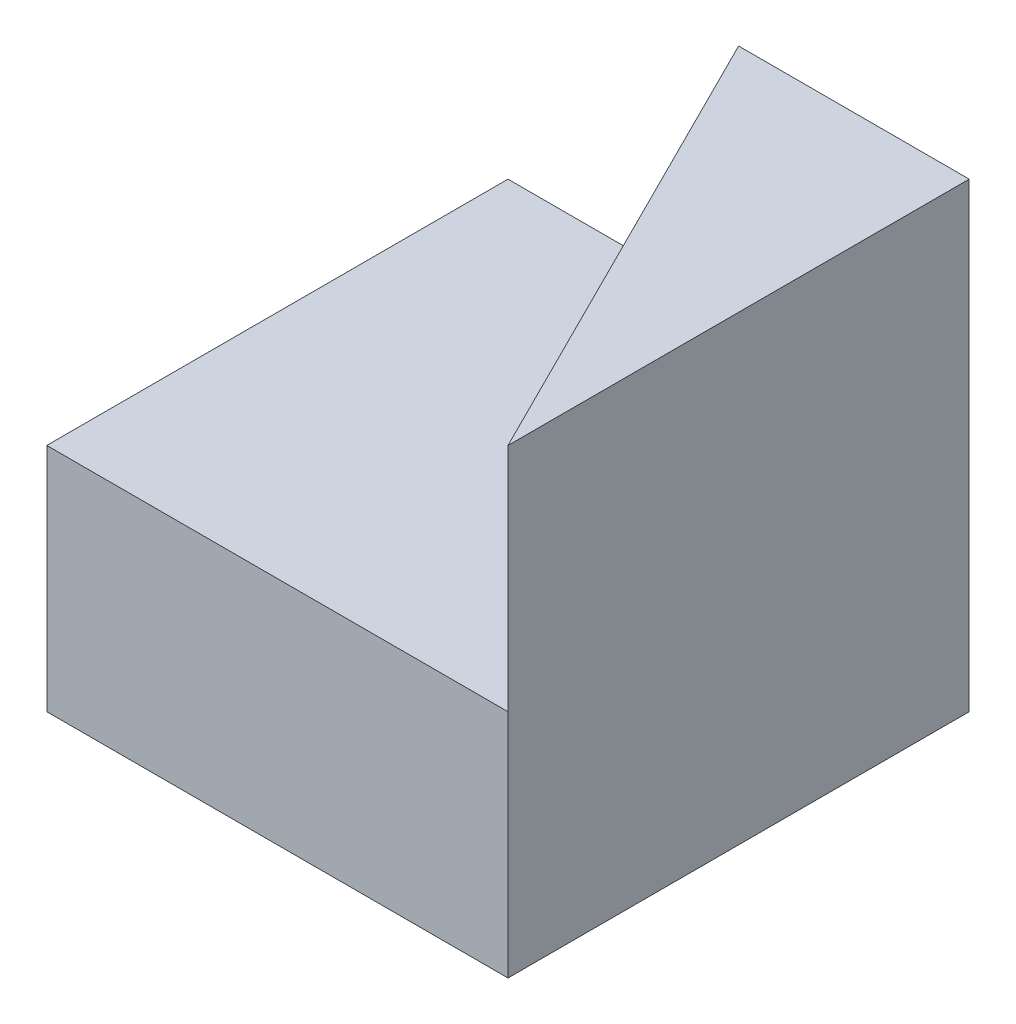
from build123d import *

# Parameters (mm, degrees)
SKETCH1_W           = 40
SKETCH1_H           = 20
BOSS_EXTRUDE2_DEPTH = 40
CUT_EXTRUDE1_DEPTH  = 40
BOSS_EXTRUDE3_DEPTH = 20
BOSS_EXTRUDE4_DEPTH = 20
CUT_EXTRUDE2_DEPTH  = 20
SKETCH6_W           = 20
SKETCH6_H           = 20
CUT_EXTRUDE3_DEPTH  = 109
BOSS_EXTRUDE5_DEPTH = 20
BOSS_EXTRUDE6_DEPTH = 20
CUT_EXTRUDE5_DEPTH  = 20


with BuildPart() as part:
    # Sketch1 → Boss-Extrude2 (new body)
    with BuildSketch(Plane.XY):
        with Locations((20, 10)):
            Rectangle(SKETCH1_W, SKETCH1_H)
    extrude(amount=BOSS_EXTRUDE2_DEPTH)

    # Sketch2 → Cut-Extrude1 (cut)
    with BuildSketch(Plane(origin=(0, 20, 0), x_dir=(1, 0, 0), z_dir=(0, 1, 0))):
        Polygon((0, -40), (20, 0), (0, 0), align=None)
    extrude(amount=-CUT_EXTRUDE1_DEPTH, mode=Mode.SUBTRACT)

    # Sketch3 → Boss-Extrude3 (add)
    with BuildSketch(Plane(origin=(0, 20, 0), x_dir=(1, 0, 0), z_dir=(0, 1, 0))):
        Polygon((40, -40), (40, 0), (20, -40), align=None)
    extrude(amount=BOSS_EXTRUDE3_DEPTH)

    # Sketch4 → Boss-Extrude4 (add)
    with BuildSketch(Plane(origin=(0, 20, 0), x_dir=(1, 0, 0), z_dir=(0, 1, 0))):
        Polygon((0, -40), (20, 0), (40, 0), (20, -40), align=None)
    extrude(amount=BOSS_EXTRUDE4_DEPTH)

    # Sketch5 → Cut-Extrude2 (cut)
    with BuildSketch(Plane(origin=(0, 40, 0), x_dir=(1, 0, 0), z_dir=(0, 1, 0))):
        Polygon((40, 0), (20, -40), (40, -40), align=None)
    extrude(amount=-CUT_EXTRUDE2_DEPTH, mode=Mode.SUBTRACT)

    # Sketch6 → Cut-Extrude3 (cut)
    with BuildSketch(Plane.XY.offset(40)):
        with Locations((10, 30)):
            Rectangle(SKETCH6_W, SKETCH6_H)
    extrude(amount=-CUT_EXTRUDE3_DEPTH, mode=Mode.SUBTRACT)

    # Sketch7 → Boss-Extrude5 (add)
    with BuildSketch(Plane(origin=(0, 20, 0), x_dir=(1, 0, 0), z_dir=(0, 1, 0))):
        Polygon((20, 0), (0, 0), (0, -40), align=None)
    extrude(amount=-BOSS_EXTRUDE5_DEPTH)

    # Sketch8 → Boss-Extrude6 (add)
    with BuildSketch(Plane(origin=(0, 20, 0), x_dir=(1, 0, 0), z_dir=(0, 1, 0))):
        Polygon((20, -40), (40, -40), (40, 0), align=None)
    extrude(amount=BOSS_EXTRUDE6_DEPTH)

    # Sketch9 → Cut-Extrude5 (cut)
    with BuildSketch(Plane(origin=(0, 40, 0), x_dir=(1, 0, 0), z_dir=(0, 1, 0))):
        Polygon((20, -40), (30, -20), (20, 0), align=None)
        Polygon((40, -40), (30, -20), (20, -40), align=None)
    extrude(amount=-CUT_EXTRUDE5_DEPTH, mode=Mode.SUBTRACT)


solid = part.part
